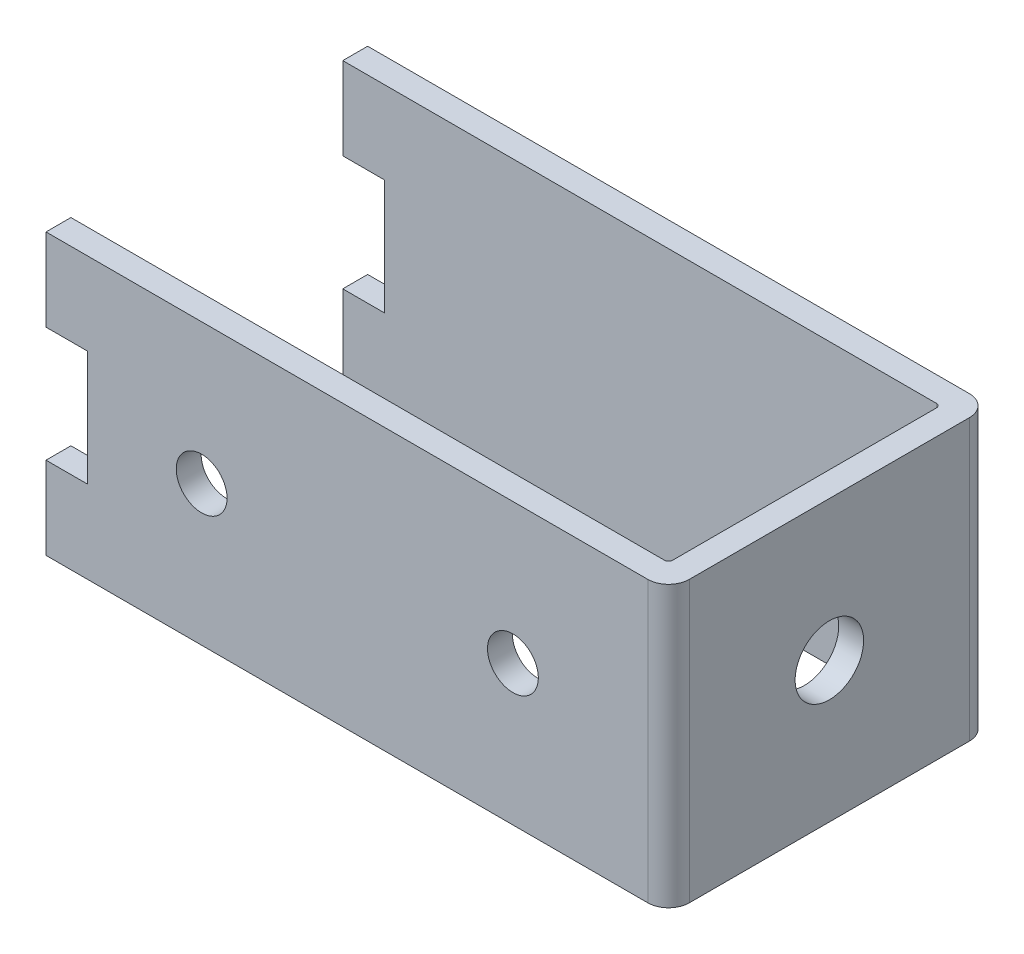
from build123d import *

# Parameters (mm, degrees)
CROQUIS1_W                 = 30
CROQUIS1_H                 = 15.5
SALIENTE_EXTRUIR1_DEPTH    = 6.75
CROQUIS2_W                 = 28.8
CROQUIS2_H                 = 13.1
CORTAR_EXTRUIR1_DEPTH      = 7.75
CORTAR_EXTRUIR1_DEPTH_BACK = 7.75
CORTAR_EXTRUIR2_REACH      = 32
CROQUIS3_R                 = 1.65
REDONDEO1_R                = 1
REDONDEO2_R                = 0.2
CROQUIS4_W                 = 2
CROQUIS4_H                 = 5.55
CORTAR_EXTRUIR3_DEPTH      = 8.75
CORTAR_EXTRUIR3_DEPTH_BACK = 8.75
CORTAR_EXTRUIR4_REACH      = 17.5
CROQUIS5_R                 = 1.225


with BuildPart() as part:
    # Croquis1 → Saliente-Extruir1 (new body, symmetric)
    with BuildSketch(Plane(origin=(0, 0, 0), x_dir=(1, 0, 0), z_dir=(0, 1, 0))):
        Rectangle(CROQUIS1_W, CROQUIS1_H)
    extrude(amount=SALIENTE_EXTRUIR1_DEPTH, both=True)

    # Croquis2 → Cortar-Extruir1 (cut, two sides)
    with BuildSketch(Plane(origin=(0, 0, 0), x_dir=(1, 0, 0), z_dir=(0, 1, 0))) as cortar_extruir1_sk:
        with Locations((-0.6, 0)):
            Rectangle(CROQUIS2_W, CROQUIS2_H)
    extrude(amount=CORTAR_EXTRUIR1_DEPTH, mode=Mode.SUBTRACT)
    extrude(cortar_extruir1_sk.sketch, amount=-CORTAR_EXTRUIR1_DEPTH_BACK, mode=Mode.SUBTRACT)

    # Croquis3 → Cortar-Extruir2 (cut, up to next)
    with BuildSketch(Plane(origin=(15, 0, 0), x_dir=(0, 0, -1), z_dir=(1, 0, 0)), mode=Mode.PRIVATE) as cortar_extruir2_sk1:
        Circle(CROQUIS3_R)
    cortar_extruir2_tool1 = extrude(cortar_extruir2_sk1.sketch, amount=-CORTAR_EXTRUIR2_REACH, mode=Mode.PRIVATE) & part.part
    add(cortar_extruir2_tool1.solids().sort_by_distance((15, 0, 0))[0], mode=Mode.SUBTRACT)

    # Redondeo1
    redondeo1_edges = [part.edges().sort_by_distance(p)[0] for p in [
        (15, 0, -7.75),
        (15, 0, 7.75),
    ]]
    fillet(redondeo1_edges, radius=REDONDEO1_R)

    # Redondeo2
    redondeo2_edges = [part.edges().sort_by_distance(p)[0] for p in [
        (13.8, 0, -6.55),
        (13.8, 0, 6.55),
    ]]
    fillet(redondeo2_edges, radius=REDONDEO2_R)

    # Croquis4 → Cortar-Extruir3 (cut, two sides)
    with BuildSketch(Plane.XY) as cortar_extruir3_sk:
        with Locations((-14, 0)):
            Rectangle(CROQUIS4_W, CROQUIS4_H)
    extrude(amount=CORTAR_EXTRUIR3_DEPTH, mode=Mode.SUBTRACT)
    extrude(cortar_extruir3_sk.sketch, amount=-CORTAR_EXTRUIR3_DEPTH_BACK, mode=Mode.SUBTRACT)

    # Croquis5 → Cortar-Extruir4 (cut, up to next)
    with BuildSketch(Plane.XY.offset(7.75), mode=Mode.PRIVATE) as cortar_extruir4_sk1:
        with Locations((-7.5, 0)):
            Circle(CROQUIS5_R)
    cortar_extruir4_tool1 = extrude(cortar_extruir4_sk1.sketch, amount=-CORTAR_EXTRUIR4_REACH, mode=Mode.PRIVATE) & part.part
    add(cortar_extruir4_tool1.solids().sort_by_distance((-7.5, 0, 7.75))[0], mode=Mode.SUBTRACT)
    # Croquis5 → Cortar-Extruir4 (cut, up to next)
    with BuildSketch(Plane.XY.offset(7.75), mode=Mode.PRIVATE) as cortar_extruir4_sk2:
        with Locations((7.5, 0)):
            Circle(CROQUIS5_R)
    cortar_extruir4_tool2 = extrude(cortar_extruir4_sk2.sketch, amount=-CORTAR_EXTRUIR4_REACH, mode=Mode.PRIVATE) & part.part
    add(cortar_extruir4_tool2.solids().sort_by_distance((7.5, 0, 7.75))[0], mode=Mode.SUBTRACT)


solid = part.part
